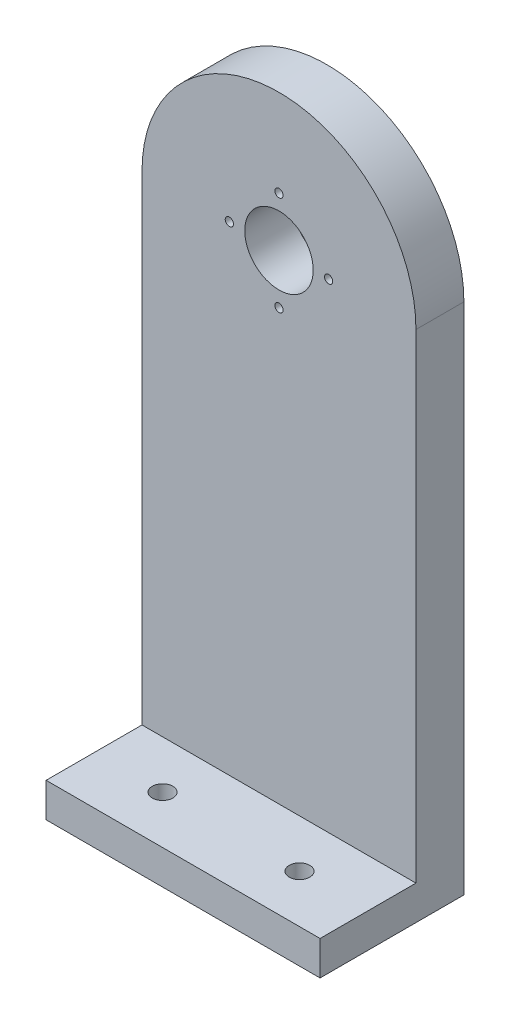
from build123d import *

# Parameters (mm, degrees)
SKETCH1_R           = 5
SKETCH1_R_2         = 0.6
BOSS_EXTRUDE1_DEPTH = 7
SKETCH2_W           = 40
SKETCH2_H           = 5
BOSS_EXTRUDE2_DEPTH = 14
SKETCH3_R           = 1.5
CUT_EXTRUDE1_DEPTH  = 6


with BuildPart() as part:
    # Sketch1 → Boss-Extrude1 (new body)
    with BuildSketch(Plane.XY):
        with BuildLine():
            Line((20, 0), (20, -75))
            Line((20, -75), (-20, -75))
            Line((-20, -75), (-20, 0))
            ThreePointArc((-20, 0), (0, 20), (20, 0))
        make_face()
        Circle(SKETCH1_R, mode=Mode.SUBTRACT)
        with Locations((0, 7.25)):
            Circle(SKETCH1_R_2, mode=Mode.SUBTRACT)
        with Locations((-7.25, 0)):
            Circle(SKETCH1_R_2, mode=Mode.SUBTRACT)
        with Locations((0, -7.25)):
            Circle(SKETCH1_R_2, mode=Mode.SUBTRACT)
        with Locations((7.25, 0)):
            Circle(SKETCH1_R_2, mode=Mode.SUBTRACT)
    extrude(amount=BOSS_EXTRUDE1_DEPTH)

    # Sketch2 → Boss-Extrude2 (add)
    with BuildSketch(Plane.XY.offset(7)):
        with Locations((0, -72.5)):
            Rectangle(SKETCH2_W, SKETCH2_H)
    extrude(amount=BOSS_EXTRUDE2_DEPTH)

    # Sketch3 → Cut-Extrude1 (cut, through all)
    with BuildSketch(Plane(origin=(0, -70, 0), x_dir=(1, 0, 0), z_dir=(0, 1, 0))):
        with Locations((-10, -14)):
            Circle(SKETCH3_R)
        with Locations((10, -14)):
            Circle(SKETCH3_R)
    extrude(amount=-CUT_EXTRUDE1_DEPTH, mode=Mode.SUBTRACT)


solid = part.part
